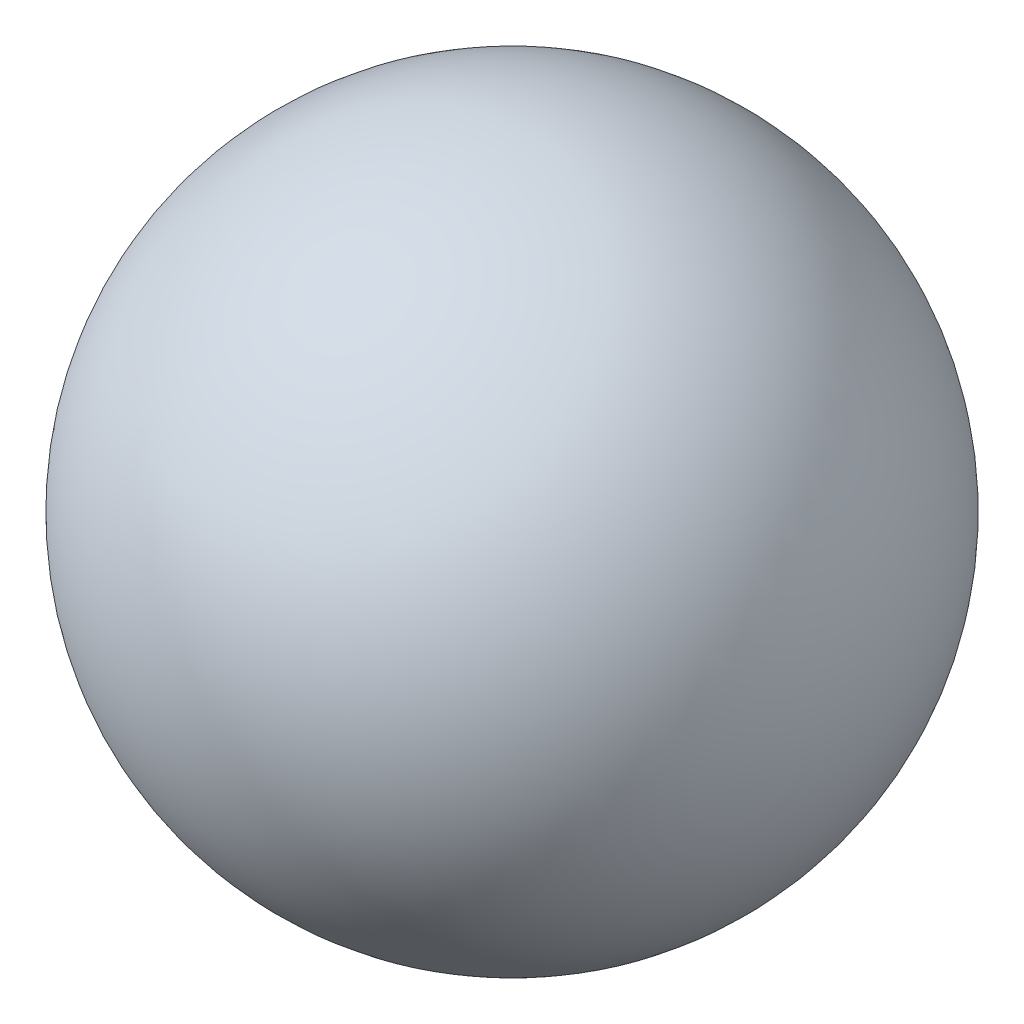
from build123d import *


with BuildPart() as part:
    # Sketch1 → Revolve1 (revolve)
    with BuildSketch(Plane.XY):
        with BuildLine():
            Line((0, 32.848331485), (0, -9.851668515))
            ThreePointArc((0, -9.851668515), (21.35, 11.498331485), (0, 32.848331485))
        make_face()
    revolve(axis=Axis((0, 32.848331485, 0), (0, -1, 0)))


solid = part.part
